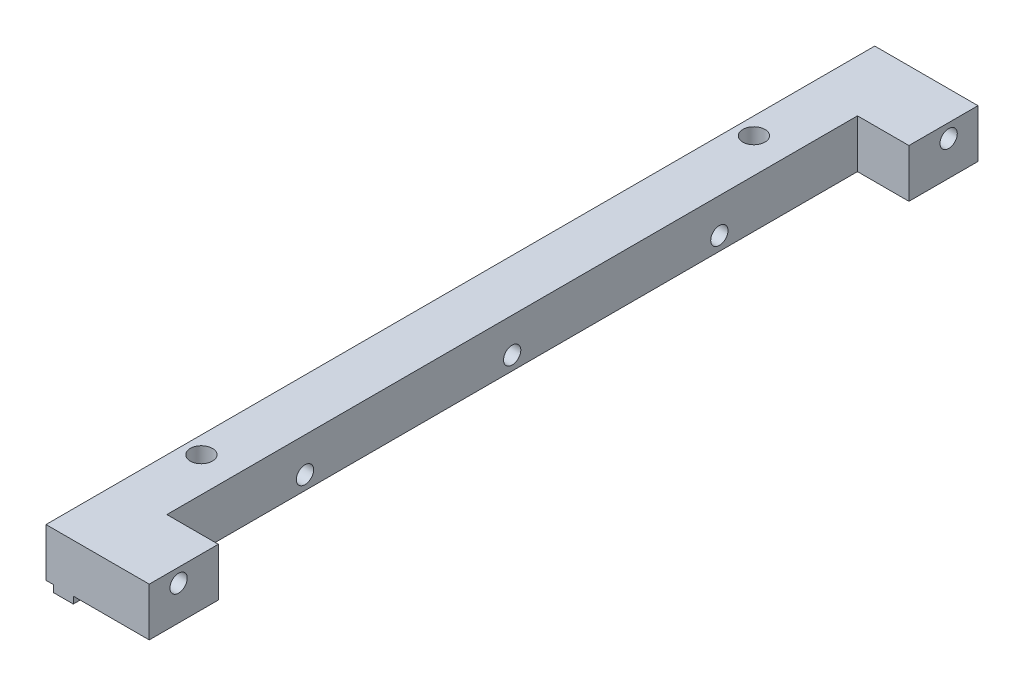
from build123d import *

# Parameters (mm, degrees)
MAIN_DEPTH               = 120
ESQUISSE2_R              = 1.25
HOLESFORMOTORBOARD_DEPTH = 15.95
ESQUISSE4_R              = 1.6
HOLESFORMAKERBEAM_DEPTH  = 9
SKETCH1_W                = 100
SKETCH1_H                = 7
POWERBOARDPINHOLES_DEPTH = 7.45
SKETCH2_R                = 1.25
WINDOWFIXHOLES_DEPTH     = 15.95


with BuildPart() as part:
    # Esquisse1 → Main (new body)
    with BuildSketch(Plane.XY):
        Polygon((0, 7), (14.95, 7), (14.95, 0), (3.95, 0), (3.95, -1), (1.05, -1), (1.05, 0), (0, 0), align=None)
    extrude(amount=MAIN_DEPTH)

    # Esquisse2 → HolesForMotorBoard (cut, through all)
    with BuildSketch(Plane(origin=(14.95, 0, 0), x_dir=(0, 0, -1), z_dir=(1, 0, 0))):
        with Locations((-4.25, 5)):
            Circle(ESQUISSE2_R)
        with Locations((-115.75, 5)):
            Circle(ESQUISSE2_R)
    extrude(amount=-HOLESFORMOTORBOARD_DEPTH, mode=Mode.SUBTRACT)

    # Esquisse4 → HolesForMakerBeam (cut, through all)
    with BuildSketch(Plane(origin=(0, -1, 0), x_dir=(-1, 0, 0), z_dir=(0, -1, 0))):
        with Locations((-2.5, -100)):
            Circle(ESQUISSE4_R)
        with Locations((-2.5, -20)):
            Circle(ESQUISSE4_R)
    extrude(amount=-HOLESFORMAKERBEAM_DEPTH, mode=Mode.SUBTRACT)

    # Sketch1 → PowerBoardPinHoles (cut)
    with BuildSketch(Plane(origin=(14.95, 0, 0), x_dir=(0, 0, -1), z_dir=(1, 0, 0))):
        with Locations((-60, 3.5)):
            Rectangle(SKETCH1_W, SKETCH1_H)
    extrude(amount=-POWERBOARDPINHOLES_DEPTH, mode=Mode.SUBTRACT)

    # Sketch2 → WindowFixHoles (cut, through all)
    with BuildSketch(Plane.ZY):
        with Locations((60, 2)):
            Circle(SKETCH2_R)
        with Locations((30, 2)):
            Circle(SKETCH2_R)
        with Locations((90, 2)):
            Circle(SKETCH2_R)
    extrude(amount=-WINDOWFIXHOLES_DEPTH, mode=Mode.SUBTRACT)


solid = part.part
